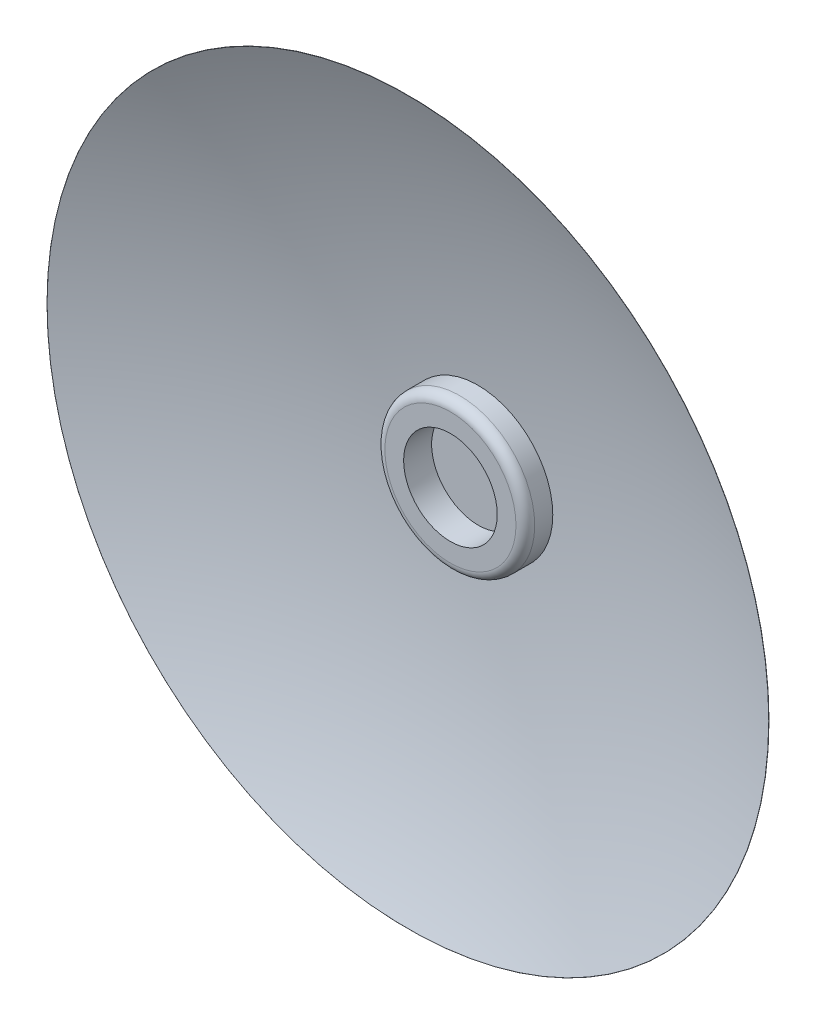
from build123d import *

# Parameters (mm, degrees)
SCALE2_SCALE       = 0.2
SKETCH3_R          = 10
CUT_EXTRUDE1_DEPTH = 65


with BuildPart() as part:
    # Sketch2 → Revolve1 (revolve)
    with BuildSketch(Plane(origin=(0, 0, 0), x_dir=(0, 0, -1), z_dir=(1, 0, 0))):
        with BuildLine():
            Line((48, 10), (48, 0))
            Line((48, 0), (398, 0))
            Line((398, 0), (398, 10))
            Line((398, 10), (375, 10))
            ThreePointArc((375, 10), (374.354166119, 45.023810067), (372.417542586, 80))
            Line((372.417542586, 80), (353.097307046, 80))
            ThreePointArc((353.097307046, 80), (346.026239234, 77.071067812), (343.097307046, 70))
            Line((343.097307046, 70), (343.097307046, 35))
            Line((343.097307046, 35), (366.168534539, 35))
            ThreePointArc((366.168534539, 35), (363.285489503, 22.450350148), (360, 10))
            Line((360, 10), (48, 10))
        make_face()
    revolve(axis=Axis((0, 0, 0), (0, 0, -1)))

    # Sketch2_4 → Revolve4 (revolve)
    with BuildSketch(Plane(origin=(0, 0, 0), x_dir=(0, 0, -1), z_dir=(1, 0, 0))):
        with BuildLine():
            Line((374.670995661, 35), (382.64097315, 35))
            ThreePointArc((382.64097315, 35), (381.418152433, 62.457340976), (379.329217835, 89.8623992))
            ThreePointArc((379.329217835, 89.8623992), (351.714253626, 241.290271622), (297.862368165, 385.487918021))
            ThreePointArc((297.862368165, 385.487918021), (297.730815988, 385.535846448), (297.680286408, 385.405271294))
            ThreePointArc((297.680286408, 385.405271294), (347.771435249, 235.81602753), (372.417542586, 80))
            ThreePointArc((372.417542586, 80), (373.100657211, 70.04284966), (373.679127274, 60.079072219))
            ThreePointArc((373.679127274, 60.079072219), (374.257887656, 47.542811856), (374.670995661, 35))
        make_face()
    revolve(axis=Axis((0, 0, 0), (0, 0, -1)))


with BuildPart() as part_1:
    # Scale2: scaled about (0, 0, -347.788992614)
    add(part.part.scale(SCALE2_SCALE).moved(Location((0, 0, -278.231194091))))

    # Sketch3 → Cut-Extrude1 (cut)
    with BuildSketch(Plane.XY.offset(-287.831194091)):
        Circle(SKETCH3_R)
    extrude(amount=-CUT_EXTRUDE1_DEPTH, mode=Mode.SUBTRACT)


solid = part_1.part
